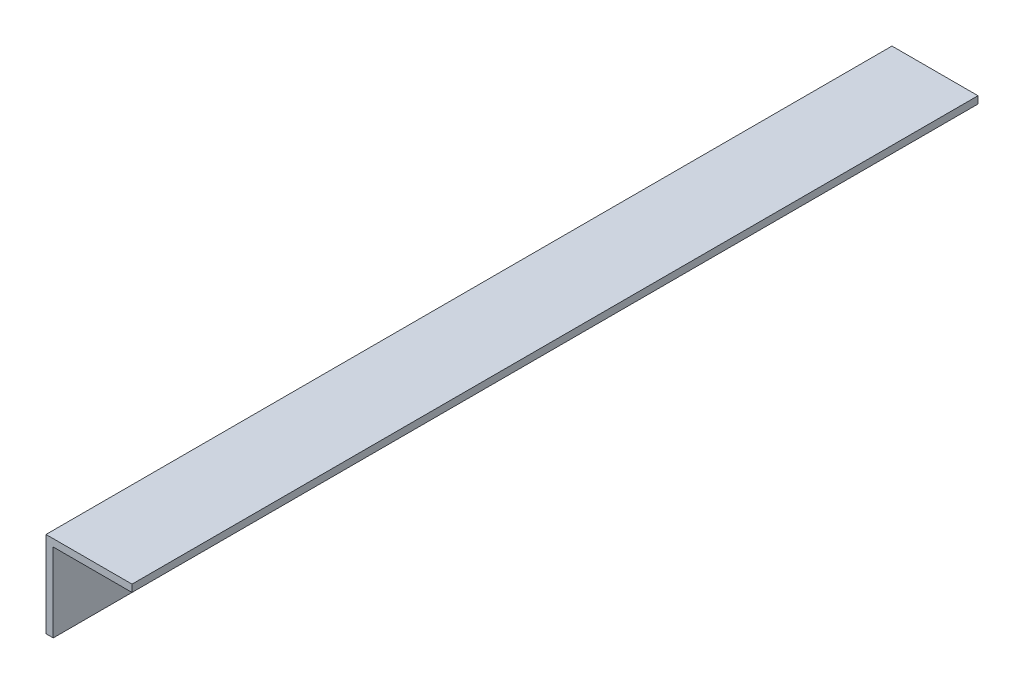
from build123d import *

# Parameters (mm, degrees)
BOSS_EXTRUDE1_DEPTH = 187.325


with BuildPart() as part:
    # Sketch1 → Boss-Extrude1 (new body)
    with BuildSketch(Plane.XY):
        Polygon((0, 0), (0, 19.05), (19.05, 19.05), (19.05, 17.4498), (1.6002, 17.4498), (1.6002, 0), align=None)
    extrude(amount=BOSS_EXTRUDE1_DEPTH)


solid = part.part
